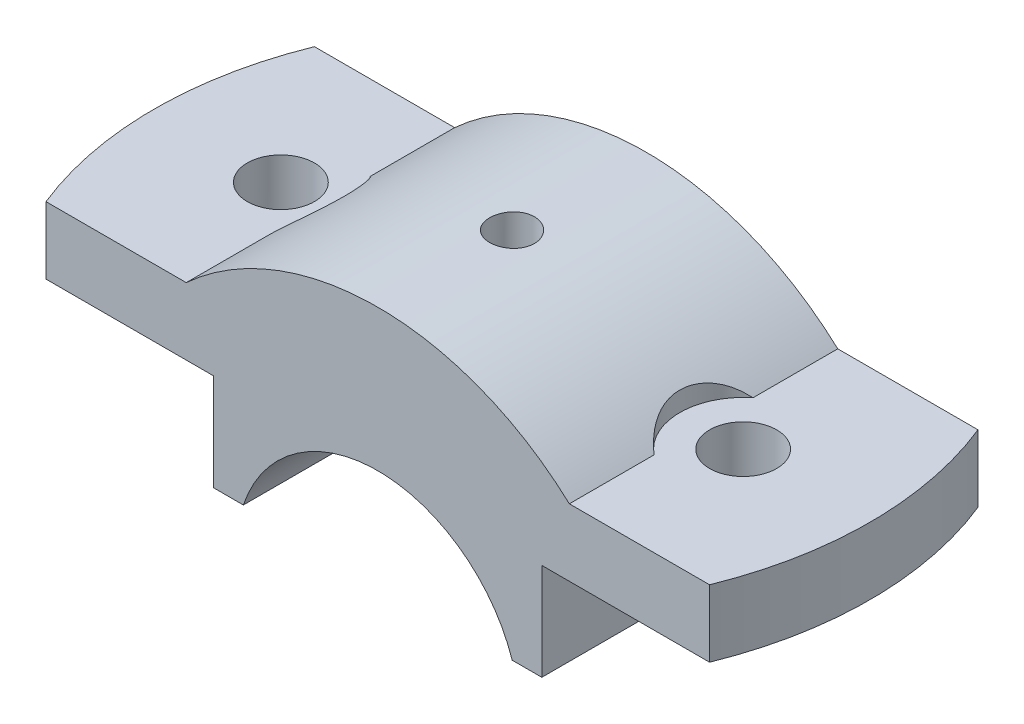
from build123d import *

# Parameters (mm, degrees)
BOSS_EXTRUDE1_DEPTH                 = 18
F_1_0MM_DOWEL_HOLE1_D               = 9
CUT_EXTRUDE1_DEPTH                  = 36
F_1_0MM_DOWEL_HOLE2_D               = 6
F_1_0MM_DOWEL_HOLE2_DEPTH           = 13
F_1_0MM_DOWEL_HOLE2_TIP             = 1.802581857
F_1_0MM_DOWEL_HOLE2_ON_FACE_2_D     = 6
F_1_0MM_DOWEL_HOLE2_ON_FACE_2_DEPTH = 13
F_1_0MM_DOWEL_HOLE2_ON_FACE_2_TIP   = 1.802581857
F_1_0MM_DOWEL_HOLE4_D               = 5
F_1_0MM_DOWEL_HOLE4_ON_FACE_2_D     = 5
CUT_EXTRUDE2_DEPTH                  = 10


with BuildPart() as part:
    # Sketch2 → Boss-Extrude1 (new body, symmetric)
    with BuildSketch(Plane.XY):
        with BuildLine():
            Line((18.027756377, 6), (22, 6))
            Line((22, 6), (22, 19))
            Line((22, 19), (50, 19))
            Line((50, 19), (50, 28))
            Line((50, 28), (25.690465157, 28))
            ThreePointArc((25.690465157, 28), (0, 38), (-25.690465157, 28))
            Line((-25.690465157, 28), (-50, 28))
            Line((-50, 28), (-50, 19))
            Line((-50, 19), (-22, 19))
            Line((-22, 19), (-22, 6))
            Line((-22, 6), (-18.027756377, 6))
            ThreePointArc((-18.027756377, 6), (0, 19), (18.027756377, 6))
        make_face()
    extrude(amount=BOSS_EXTRUDE1_DEPTH, both=True)

    # Ø1.0mm Dowel Hole1 (through all)
    with Locations(Plane(origin=(0, 28, 0), x_dir=(1, 0, 0), z_dir=(0, 1, 0))):
        with Locations((31, 0)):
            f_1_0mm_dowel_hole1 = Hole(F_1_0MM_DOWEL_HOLE1_D / 2)

    # Sketch7 → Cut-Extrude1 (cut)
    with BuildSketch(Plane(origin=(0, 28, 0), x_dir=(1, 0, 0), z_dir=(0, 1, 0))):
        with BuildLine():
            Line((50, 18), (44.497190923, 18))
            ThreePointArc((44.497190923, 18), (48, 0), (44.497190923, -18))
            Line((44.497190923, -18), (50, -18))
            Line((50, -18), (50, 18))
        make_face()
    cut_extrude1 = extrude(amount=-CUT_EXTRUDE1_DEPTH, mode=Mode.SUBTRACT)

    # Ø1.0mm Dowel Hole2
    with Locations(Plane(origin=(0, 38, 0), x_dir=(1, 0, 0), z_dir=(0, 1, 0))):
        with Locations((0, 0)):
            Hole(F_1_0MM_DOWEL_HOLE2_D / 2, depth=F_1_0MM_DOWEL_HOLE2_DEPTH)
            with Locations((0, 0, -(F_1_0MM_DOWEL_HOLE2_DEPTH + F_1_0MM_DOWEL_HOLE2_TIP / 2))):  # 118° drill point
                Cone(0, F_1_0MM_DOWEL_HOLE2_D / 2, F_1_0MM_DOWEL_HOLE2_TIP, mode=Mode.SUBTRACT)

    # Ø1.0mm Dowel Hole2 on face 2
    with Locations(Plane(origin=(0, 0, 0), x_dir=(1, 0, 0), z_dir=(0, 1, 0))):
        with Locations((0, 0)):
            Hole(F_1_0MM_DOWEL_HOLE2_ON_FACE_2_D / 2, depth=F_1_0MM_DOWEL_HOLE2_ON_FACE_2_DEPTH)
            with Locations((0, 0, -(F_1_0MM_DOWEL_HOLE2_ON_FACE_2_DEPTH + F_1_0MM_DOWEL_HOLE2_ON_FACE_2_TIP / 2))):  # 118° drill point
                Cone(0, F_1_0MM_DOWEL_HOLE2_ON_FACE_2_D / 2, F_1_0MM_DOWEL_HOLE2_ON_FACE_2_TIP, mode=Mode.SUBTRACT)

    # Ø1.0mm Dowel Hole4 (through all)
    with Locations(Plane(origin=(0, 19, 0), x_dir=(-1, 0, 0), z_dir=(0, -1, 0))):
        with Locations((0, 0)):
            Hole(F_1_0MM_DOWEL_HOLE4_D / 2)

    # Ø1.0mm Dowel Hole4 on face 2 (through all)
    with Locations(Plane(origin=(0, 0, 0), x_dir=(-1, 0, 0), z_dir=(0, -1, 0))):
        with Locations((0, 0)):
            Hole(F_1_0MM_DOWEL_HOLE4_ON_FACE_2_D / 2)

    # Mirror1: Ø1.0mm Dowel Hole1, Cut-Extrude1 across plane
    add(f_1_0mm_dowel_hole1.mirror(Plane(origin=(0, 0, 0), x_dir=(0, 0, 1), z_dir=(1, 0, 0))), mode=Mode.SUBTRACT)
    add(cut_extrude1.mirror(Plane(origin=(0, 0, 0), x_dir=(0, 0, 1), z_dir=(1, 0, 0))), mode=Mode.SUBTRACT)

    # Sketch16 → Cut-Extrude2 (cut)
    with BuildSketch(Plane(origin=(0, 28, 0), x_dir=(1, 0, 0), z_dir=(0, 1, 0))):
        with BuildLine():
            Line((-25.690465157, -6.637683312), (-25.690465157, 6.637683312))
            ThreePointArc((-25.690465157, 6.637683312), (-22.5, 0), (-25.690465157, -6.637683312))
        make_face()
    cut_extrude2 = extrude(amount=CUT_EXTRUDE2_DEPTH, mode=Mode.SUBTRACT)

    # Mirror2: Cut-Extrude2 across plane
    add(cut_extrude2.mirror(Plane(origin=(0, 0, 0), x_dir=(0, 0, 1), z_dir=(1, 0, 0))), mode=Mode.SUBTRACT)


solid = part.part
